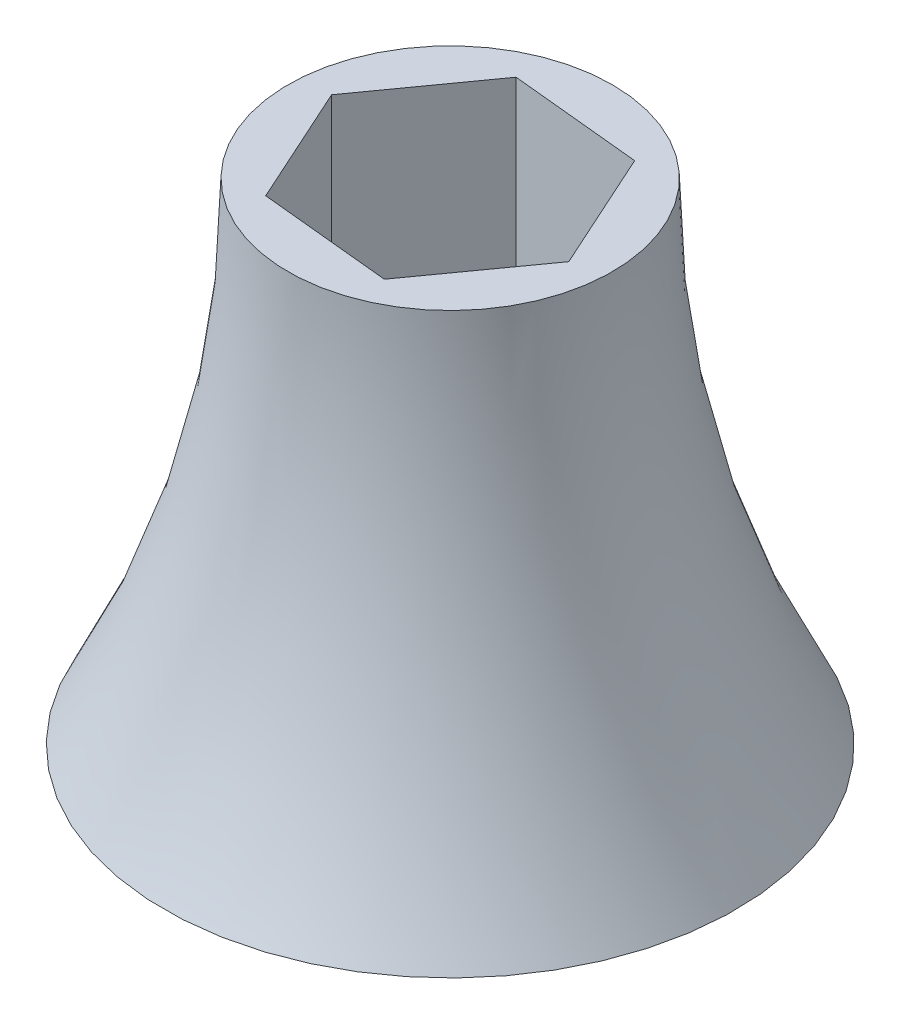
from build123d import *

# Parameters (mm, degrees)
SKETCH1_R           = 33.274
BOSS_EXTRUDE1_DEPTH = 57.15
CUT_EXTRUDE1_DEPTH  = 57.15
SKETCH4_R           = 120.65


with BuildPart() as part:
    # Sketch1 → Boss-Extrude1 (new body)
    with BuildSketch(Plane(origin=(0, 0, 0), x_dir=(1, 0, 0), z_dir=(0, 1, 0))):
        Circle(SKETCH1_R)
    extrude(amount=BOSS_EXTRUDE1_DEPTH)

    # Sketch2 → Cut-Extrude1 (cut)
    with BuildSketch(Plane.XZ):
        Polygon((-15.323636661, -1.510781079), (-6.353443536, -14.026049167), (8.970193125, -12.515268087), (15.323636661, 1.510781079), (6.353443536, 14.026049167), (-8.970193125, 12.515268087), align=None)
    extrude(amount=-CUT_EXTRUDE1_DEPTH, mode=Mode.SUBTRACT)

    # Sketch4 → Cut-Revolve2 (revolve, cut)
    with BuildSketch(Plane.XY):
        with Locations((-139.52982337, 57.15)):
            Circle(SKETCH4_R)
    revolve(axis=Axis((0, 0, 0), (0, 1, 0)), mode=Mode.SUBTRACT)


solid = part.part
